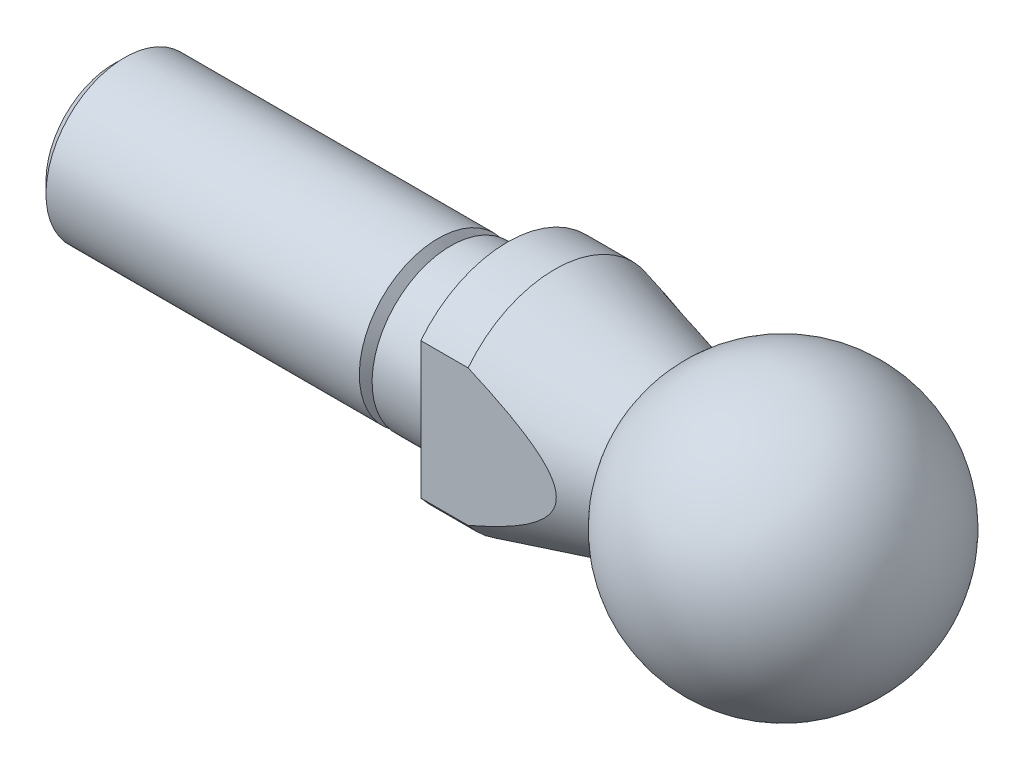
from build123d import *

# Parameters (mm, degrees)
SKETCH2_OUTSIDE_W   = 30.882
SKETCH2_OUTSIDE_H   = 30.882
SKETCH2_OUTSIDE_W_2 = 11
SKETCH2_OUTSIDE_H_2 = 14
CUT_EXTRUDE1_DEPTH  = 10.342159


with BuildPart() as part:
    # Sketch1 → Body Revolve (revolve)
    with BuildSketch(Plane.XY):
        with BuildLine():
            Line((-14.5, 7), (-17.5, 7))
            Line((-17.5, 7), (-17.5, 5))
            Line((-17.5, 5), (-21.095854812, 5))
            Line((-21.095854812, 5), (-21.5, 4.3))
            Line((-21.5, 4.3), (-21.904145188, 5))
            Line((-21.904145188, 5), (-41.8, 5))
            Line((-41.8, 5), (-42.5, 4.3))
            Line((-42.5, 4.3), (-42.5, 0))
            Line((-42.5, 0), (8.75, 0))
            ThreePointArc((8.75, 0), (2.639260414, 8.342469926), (-7.15784102, 5.032674431))
            Line((-7.15784102, 5.032674431), (-14.5, 7))
        make_face()
    revolve(axis=Axis((-9.81300365, 0, 0), (1, 0, 0)))

    # Sketch2 outside → Cut-Extrude1 (cut)
    with BuildSketch(Plane.ZY.offset(17.5)):
        Rectangle(SKETCH2_OUTSIDE_W, SKETCH2_OUTSIDE_H)
        Rectangle(SKETCH2_OUTSIDE_W_2, SKETCH2_OUTSIDE_H_2, mode=Mode.SUBTRACT)
    extrude(amount=-CUT_EXTRUDE1_DEPTH, mode=Mode.SUBTRACT)


solid = part.part
